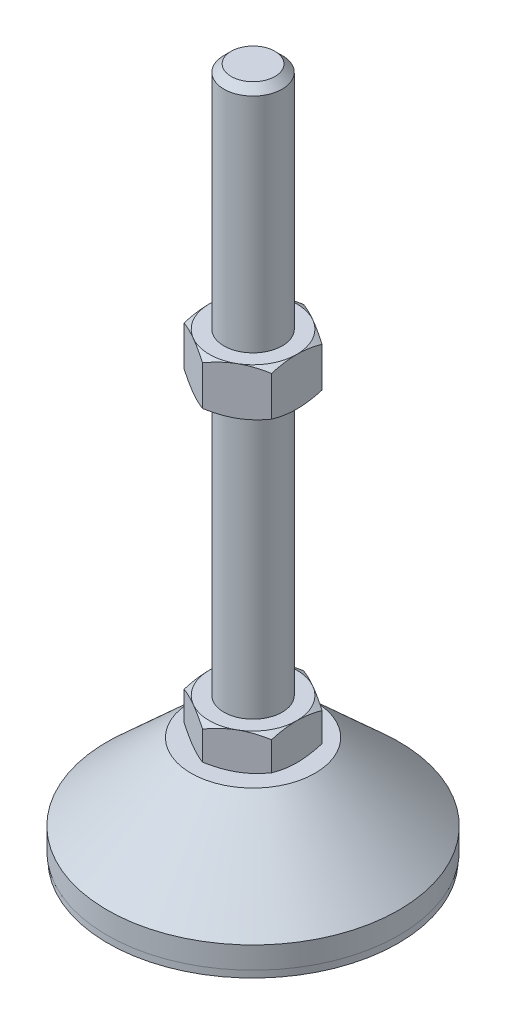
from build123d import *

# Parameters (mm, degrees)
EXTRUDE_1_DEPTH = 10
EXTRUDE_2_DEPTH = 13


with BuildPart() as part:
    # Эскиз1 → Повернуть1 (revolve)
    with BuildSketch(Plane.XY, mode=Mode.PRIVATE) as revolve_1_sk:
        Polygon((0, 0), (-39.8, 0), (-39.8, 2), (-40, 2), (-40, 8), (-17, 29), (-8, 29), (-8, 39), (-8, 187), (-6, 189), (0, 189), align=None)
    revolve(revolve_1_sk.sketch.rotate(Axis((0, 0, 0), (0, 1, 0)), 180), axis=Axis((0, 0, 0), (0, 1, 0)))  # turned: the seam where the file's is

    # Эскиз2 → Бобышка-Вытянуть1 (add)
    with BuildSketch(Plane(origin=(0, 29, 0), x_dir=(1, 0, 0), z_dir=(0, 1, 0))):
        Polygon((0, 13.856406461), (-12, 6.92820323), (-12, -6.92820323), (0, -13.856406461), (12, -6.92820323), (12, 6.92820323), align=None)
    extrude(amount=EXTRUDE_1_DEPTH)

    # Эскиз3 → Бобышка-Вытянуть2 (add)
    with BuildSketch(Plane(origin=(0, 113, 0), x_dir=(1, 0, 0), z_dir=(0, 1, 0))):
        Polygon((12, 6.92820323), (0, 13.856406461), (-12, 6.92820323), (-12, -6.92820323), (0, -13.856406461), (12, -6.92820323), align=None)
    extrude(amount=EXTRUDE_2_DEPTH)

    # Эскиз4 → Вырез-Повернуть2 (revolve, cut)
    with BuildSketch(Plane.XY, mode=Mode.PRIVATE) as cut_revolve_2_sk:
        Polygon((-23.258330249, 126), (-12, 126), (-23.258330249, 119.5), align=None)
        Polygon((-23.258330249, 113), (-23.258330249, 119.5), (-12, 113), align=None)
        Polygon((-20.660254038, 39), (-20.660254038, 34), (-12, 39), align=None)
        Polygon((-20.660254038, 34), (-20.660254038, 29), (-12, 29), align=None)
    revolve(cut_revolve_2_sk.sketch.rotate(Axis((0, 189, 0), (0, -1, 0)), 180), axis=Axis((0, 189, 0), (0, -1, 0)), mode=Mode.SUBTRACT)  # turned: the seam where the file's is


solid = part.part
